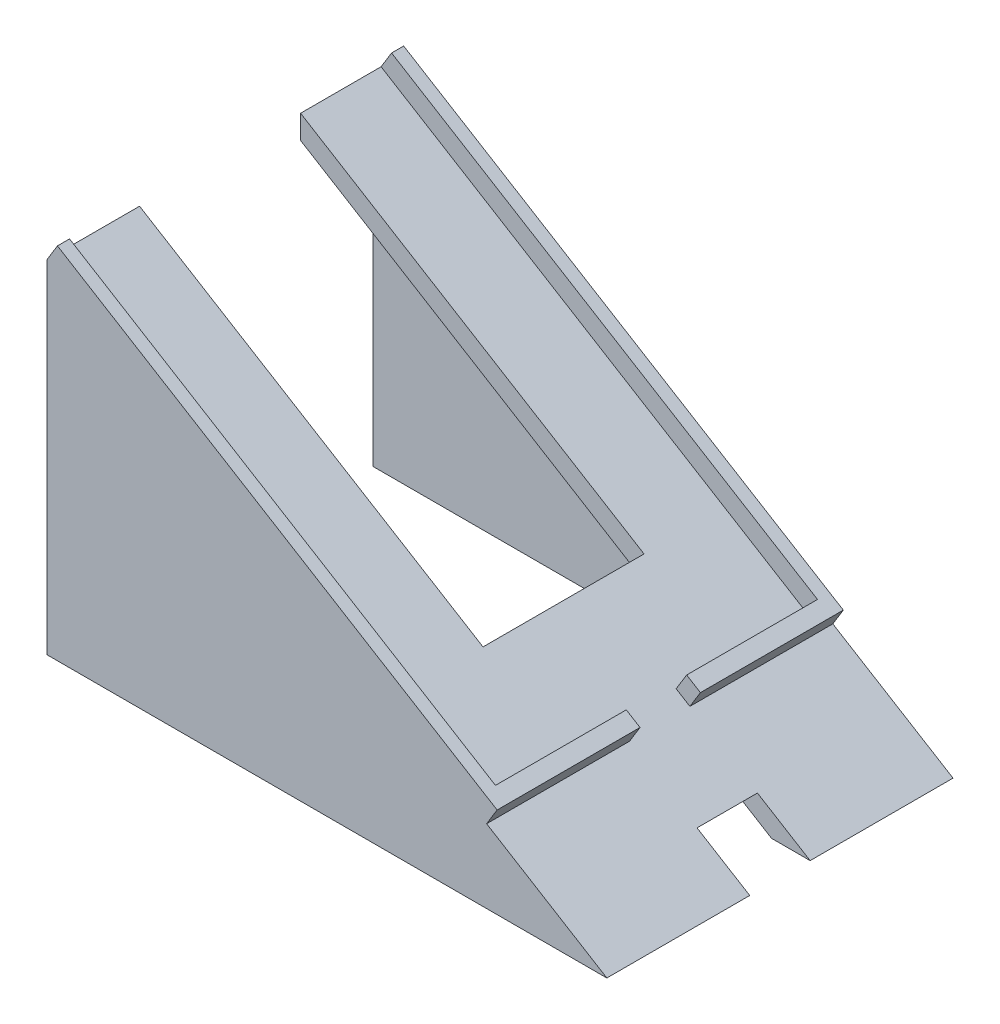
from build123d import *

# Parameters (mm, degrees)
BOSS_EXTRUDE2_DEPTH = 86
BOSS_EXTRUDE3_DEPTH = 5
BOSS_EXTRUDE4_DEPTH = 5
CUT_EXTRUDE2_DEPTH  = 82.06047469
BOSS_EXTRUDE5_DEPTH = 5
CUT_EXTRUDE3_DEPTH  = 6
SKETCH8_W           = 40
SKETCH8_H           = 5.859822581
CUT_EXTRUDE4_DEPTH  = 69.214723926
SKETCH11_W          = 86
SKETCH11_H          = 10
CUT_EXTRUDE6_DEPTH  = 140.082709206
CUT_EXTRUDE8_DEPTH  = 140.082709206
SKETCH14_W          = 15
SKETCH14_H          = 5
CUT_EXTRUDE9_DEPTH  = 10


with BuildPart() as part:
    # Sketch1 → Boss-Extrude2 (new body)
    with BuildSketch(Plane.XY):
        Polygon((0, 89.140177419), (0, 95), (139.082709206, 10), (139.082709206, 0), (0, 0), (0, 5), (5, 5), (134.082709206, 5), (134.082709206, 7.195913121), (5, 86.084441718), align=None)
    extrude(amount=BOSS_EXTRUDE2_DEPTH)

    # Sketch2 → Boss-Extrude3 (add)
    with BuildSketch(Plane.XY.offset(86)):
        Polygon((0, 89.140177419), (134.082709206, 7.195913121), (134.082709206, 5), (0, 5), align=None)
    extrude(amount=-BOSS_EXTRUDE3_DEPTH)

    # Sketch3 → Boss-Extrude4 (add)
    with BuildSketch(Plane(origin=(42.270799685, 69.166321653, 0), x_dir=(0, 0, -1), z_dir=(0.521472393, 0.853268155, 0))):
        Polygon((0, 49.539877301), (0, -78.460122699), (-86, -78.460122699), (-86, 49.539877301), (-83, 49.539877301), (-83, -74.460122699), (-3, -74.460122699), (-3, 49.539877301), align=None)
    extrude(amount=BOSS_EXTRUDE4_DEPTH)

    # Sketch5 → Cut-Extrude2 (cut, through all)
    with BuildSketch(Plane(origin=(42.270799685, 69.166321653, 0), x_dir=(0, 0, -1), z_dir=(0.521472393, 0.853268155, 0))):
        Polygon((-43, 49.539877301), (-23, 49.539877301), (-23, -50.460122699), (-63, -50.460122699), (-63, 49.539877301), align=None)
    extrude(amount=-CUT_EXTRUDE2_DEPTH, mode=Mode.SUBTRACT)

    # Sketch6 → Boss-Extrude5 (add)
    with BuildSketch(Plane(origin=(0, 0, 0), x_dir=(-1, 0, 0), z_dir=(0, 0, -1))):
        Polygon((0, 89.140177419), (-134.082709206, 7.195913121), (-134.082709206, 5), (0, 5), align=None)
    extrude(amount=-BOSS_EXTRUDE5_DEPTH)

    # Sketch7 → Cut-Extrude3 (cut, through all)
    with BuildSketch(Plane(origin=(0, 5, 0), x_dir=(1, 0, 0), z_dir=(0, 1, 0))):
        Polygon((0, -5), (135.193098296, -5), (134.082709206, -81), (0, -81), (0, -63), (62.193208986, -63), (62.193208986, -23), (0, -23), align=None)
    extrude(amount=-CUT_EXTRUDE3_DEPTH, mode=Mode.SUBTRACT)

    # Sketch8 → Cut-Extrude4 (cut, through all)
    with BuildSketch(Plane(origin=(43.056015778, -26.313560917, 0), x_dir=(0, 0, 1), z_dir=(-0.853268155, 0.521472393, 0))):
        with Locations((43, 33.768470979)):
            Rectangle(SKETCH8_W, SKETCH8_H)
    extrude(amount=-CUT_EXTRUDE4_DEPTH, mode=Mode.SUBTRACT)

    # Sketch11 → Cut-Extrude6 (cut, through all)
    with BuildSketch(Plane(origin=(139.082709206, 0, 0), x_dir=(0, 0, -1), z_dir=(1, 0, 0))):
        with Locations((-43, 5)):
            Rectangle(SKETCH11_W, SKETCH11_H)
    extrude(amount=-CUT_EXTRUDE6_DEPTH, mode=Mode.SUBTRACT)

    # Sketch13 → Cut-Extrude8 (cut, through all)
    with BuildSketch(Plane.ZY):
        Polygon((43, 10), (50.5, 10), (50.5, 18), (35.5, 18), (35.5, 10), align=None)
    extrude(amount=-CUT_EXTRUDE8_DEPTH, mode=Mode.SUBTRACT)

    # Sketch14 → Cut-Extrude9 (cut)
    with BuildSketch(Plane(origin=(66.947524108, -40.914787911, 0), x_dir=(0, 0, -1), z_dir=(0.853268155, -0.521472393, 0))):
        with Locations((-43, 83.56047469)):
            Rectangle(SKETCH14_W, SKETCH14_H)
    extrude(amount=-CUT_EXTRUDE9_DEPTH, mode=Mode.SUBTRACT)


solid = part.part
